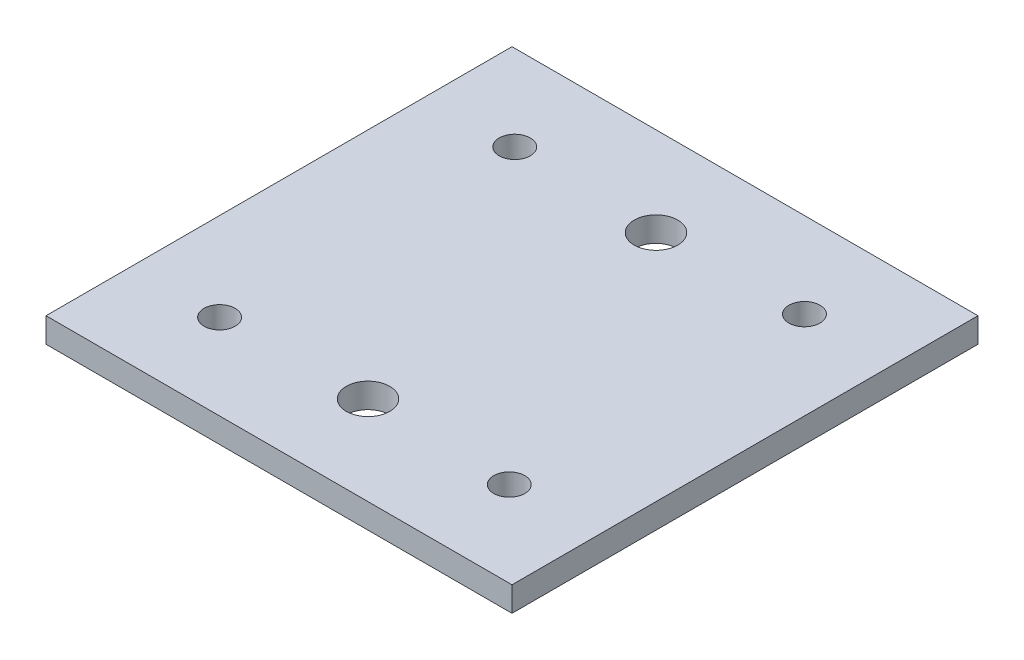
from build123d import *

# Parameters (mm, degrees)
SKETCH1_W           = 150
SKETCH1_H           = 7.962213225
BOSS_EXTRUDE1_DEPTH = 150
SKETCH2_R           = 7
CUT_EXTRUDE1_DEPTH  = 8.962213225
SKETCH3_R           = 5
CUT_EXTRUDE2_DEPTH  = 8.962213225


with BuildPart() as part:
    # Sketch1 → Boss-Extrude1 (new body)
    with BuildSketch(Plane(origin=(0, 0, 0), x_dir=(0, 0, -1), z_dir=(1, 0, 0))):
        with Locations((75, -3.981106613)):
            Rectangle(SKETCH1_W, SKETCH1_H)
    extrude(amount=BOSS_EXTRUDE1_DEPTH)

    # Sketch2 → Cut-Extrude1 (cut, through all)
    with BuildSketch(Plane(origin=(0, 0, 0), x_dir=(1, 0, 0), z_dir=(0, 1, 0))):
        with Locations((74.999907539, 121.3473939)):
            Circle(SKETCH2_R)
        with Locations((74.999907539, 28.6526061)):
            Circle(SKETCH2_R)
    extrude(amount=-CUT_EXTRUDE1_DEPTH, mode=Mode.SUBTRACT)

    # Sketch3 → Cut-Extrude2 (cut, through all)
    with BuildSketch(Plane.XZ.offset(7.962213225)):
        with Locations((28.371496461, -122.5)):
            Circle(SKETCH3_R)
        with Locations((28.371496461, -27.5)):
            Circle(SKETCH3_R)
        with Locations((121.628503539, -27.5)):
            Circle(SKETCH3_R)
        with Locations((121.628503539, -122.5)):
            Circle(SKETCH3_R)
    extrude(amount=-CUT_EXTRUDE2_DEPTH, mode=Mode.SUBTRACT)


solid = part.part
